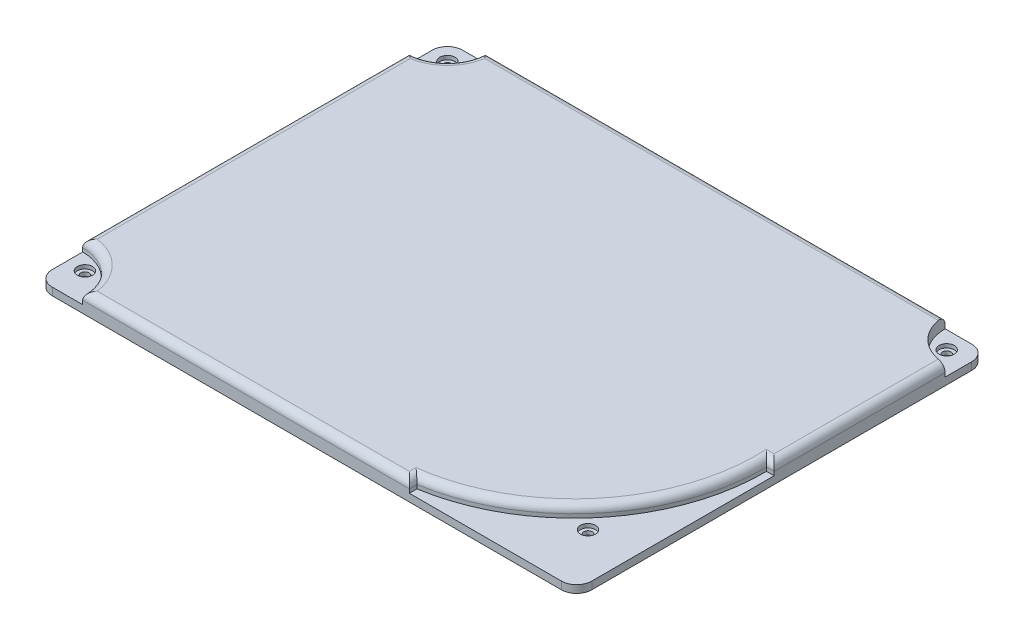
from build123d import *

# Parameters (mm, degrees)
SKETCH1_W                         = 71
SKETCH1_H                         = 54
BOSS_EXTRUDE1_DEPTH               = 2.5
M1_4X0_3_TAPPED_HOLE1_D           = 1.1
M1_4X0_3_TAPPED_HOLE1_CSINK_D     = 1.45
M1_4X0_3_TAPPED_HOLE1_CSINK_ANGLE = 90
CUT_EXTRUDE1_DEPTH                = 1.8
SKETCH5_R                         = 6
SKETCH5_R_2                       = 5
SKETCH5_R_3                       = 5.5
CUT_EXTRUDE2_DEPTH                = 1.5
FILLET1_R                         = 2
FILLET2_R                         = 1
SKETCH6_R                         = 1
CUT_EXTRUDE4_DEPTH                = 0.5


with BuildPart() as part:
    # Sketch1 → Boss-Extrude1 (new body)
    with BuildSketch(Plane(origin=(0, 0, 0), x_dir=(1, 0, 0), z_dir=(0, 1, 0))):
        Rectangle(SKETCH1_W, SKETCH1_H)
    extrude(amount=BOSS_EXTRUDE1_DEPTH)

    # M1.4x0.3 Tapped Hole1 (through all)
    with Locations(Plane(origin=(0, 2.5, 0), x_dir=(1, 0, 0), z_dir=(0, 1, 0))):
        with Locations((-33.2, 24.7), (32.5, 24.7), (-33.2, -23), (29.4, -19.4)):
            CounterSinkHole(M1_4X0_3_TAPPED_HOLE1_D / 2, M1_4X0_3_TAPPED_HOLE1_CSINK_D / 2, counter_sink_angle=M1_4X0_3_TAPPED_HOLE1_CSINK_ANGLE)

    # Sketch4 → Cut-Extrude1 (cut)
    with BuildSketch(Plane.XZ):
        with BuildLine():
            Line((-7.748076809, 19), (-33.5, 19))
            Line((-33.5, 19), (-33.5, -20))
            Line((-33.5, -20), (-6.5, -20))
            ThreePointArc((-6.5, -20), (33.487208249, 0.799639875), (-7.748076809, 19))
        make_face()
    extrude(amount=-CUT_EXTRUDE1_DEPTH, mode=Mode.SUBTRACT)

    # Sketch5 → Cut-Extrude2 (cut)
    with BuildSketch(Plane(origin=(0, 2.5, 0), x_dir=(1, 0, 0), z_dir=(0, 1, 0))):
        with Locations((-35.5, -27)):
            Circle(SKETCH5_R)
        with Locations((-35.5, 27)):
            Circle(SKETCH5_R_2)
        with Locations((35.5, 27)):
            Circle(SKETCH5_R_3)
        with BuildLine():
            Line((34.5, -1), (35.5, -1))
            Line((35.5, -1), (35.5, -27))
            Line((35.5, -27), (13.5, -27))
            Line((13.5, -27), (13.5, -26))
            ThreePointArc((13.5, -26), (28.644692027, -17.401541303), (34.5, -1))
        make_face()
    extrude(amount=-CUT_EXTRUDE2_DEPTH, mode=Mode.SUBTRACT)

    # Fillet1
    fillet1_edges = [part.edges().sort_by_distance(p)[0] for p in [
        (35.5, 0.5, 27),
        (-35.5, 0.5, 27),
        (-35.5, 0.5, -27),
        (35.5, 0.5, -27),
    ]]
    fillet(fillet1_edges, radius=FILLET1_R)

    # Fillet2
    fillet2_edges = [part.edges().sort_by_distance(p)[0] for p in [
        (-8, 2.5, 27),
        (-35.5, 2.5, -0.5),
        (-0.25, 2.5, -27),
        (35.5, 2.5, -10.25),
        (28.644692027, 2.5, 17.401541303),
        (13.5, 2.5, 26.5),
        (35, 2.5, 1),
        (-31.964466094, 2.5, -23.464466094),
        (-31.257359313, 2.5, 22.757359313),
    ]]
    fillet(fillet2_edges, radius=FILLET2_R)

    # Sketch6 → Cut-Extrude4 (cut)
    with BuildSketch(Plane(origin=(0, 1, 0), x_dir=(1, 0, 0), z_dir=(0, 1, 0))):
        with Locations((-33.2, 24.7)):
            Circle(SKETCH6_R)
        with Locations((32.5, 24.7)):
            Circle(SKETCH6_R)
        with Locations((29.4, -19.4)):
            Circle(SKETCH6_R)
        with Locations((-33.2, -23)):
            Circle(SKETCH6_R)
    extrude(amount=-CUT_EXTRUDE4_DEPTH, mode=Mode.SUBTRACT)


solid = part.part
